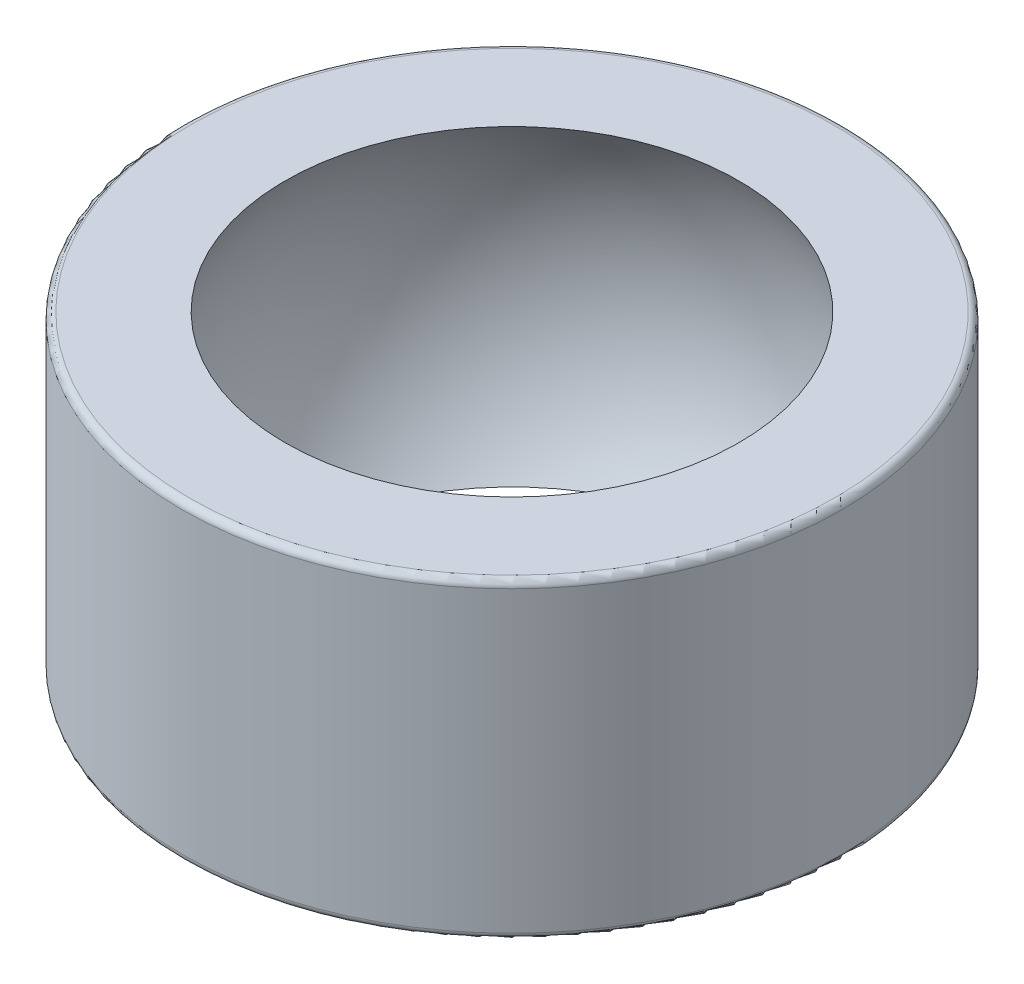
from build123d import *

# Parameters (mm, degrees)
SZKIC1_R                    = 9.5
DODANIE_WYCI_GNI_CIE1_DEPTH = 4.5
ZAOKR_GLENIE1_R             = 0.2


with BuildPart() as part:
    # Szkic1 → Dodanie-wyciągnięcie1 (new body, symmetric)
    with BuildSketch(Plane(origin=(0, 0, 0), x_dir=(1, 0, 0), z_dir=(0, 1, 0))):
        Circle(SZKIC1_R)
    extrude(amount=DODANIE_WYCI_GNI_CIE1_DEPTH, both=True)

    # Szkic3 → Wycięcie-obrót1 (revolve, cut)
    with BuildSketch(Plane.XY):
        with BuildLine():
            Line((0, -7.94), (0, 7.94))
            ThreePointArc((0, 7.94), (7.94, 0), (0, -7.94))
        make_face()
    revolve(axis=Axis((0, -7.94, 0), (0, 1, 0)), mode=Mode.SUBTRACT)

    # Zaokrąglenie1
    zaokr_glenie1_edges = [part.edges().sort_by_distance(p)[0] for p in [
        (-9.5, -4.5, 0),
        (-9.5, 4.5, 0),
    ]]
    fillet(zaokr_glenie1_edges, radius=ZAOKR_GLENIE1_R)


solid = part.part
